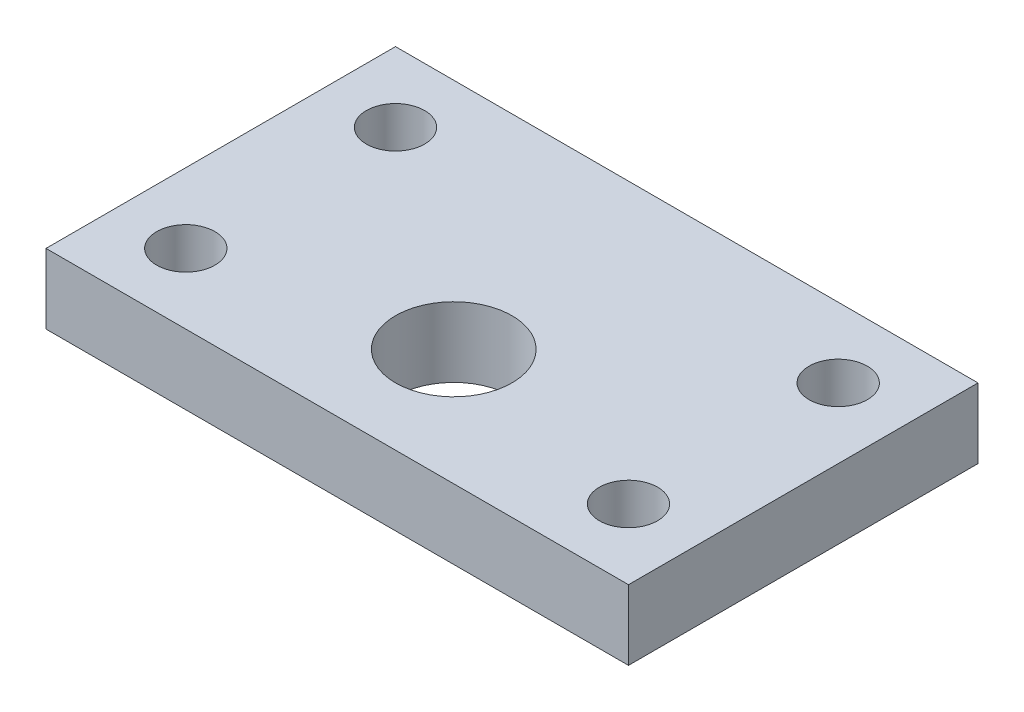
from build123d import *

# Parameters (mm, degrees)
SKETCH1_W           = 250
SKETCH1_H           = 150
SKETCH1_R           = 12.5
SKETCH1_R_2         = 25
BOSS_EXTRUDE1_DEPTH = 30


with BuildPart() as part:
    # Sketch1 → Boss-Extrude1 (new body)
    with BuildSketch(Plane(origin=(0, 0, 0), x_dir=(1, 0, 0), z_dir=(0, 1, 0))):
        with Locations((125, 75)):
            Rectangle(SKETCH1_W, SKETCH1_H)
        with Locations((30, 30)):
            Circle(SKETCH1_R, mode=Mode.SUBTRACT)
        with Locations((30, 120)):
            Circle(SKETCH1_R, mode=Mode.SUBTRACT)
        with Locations((220, 120)):
            Circle(SKETCH1_R, mode=Mode.SUBTRACT)
        with Locations((220, 30)):
            Circle(SKETCH1_R, mode=Mode.SUBTRACT)
        with Locations((125, 50)):
            Circle(SKETCH1_R_2, mode=Mode.SUBTRACT)
    extrude(amount=BOSS_EXTRUDE1_DEPTH)


solid = part.part
